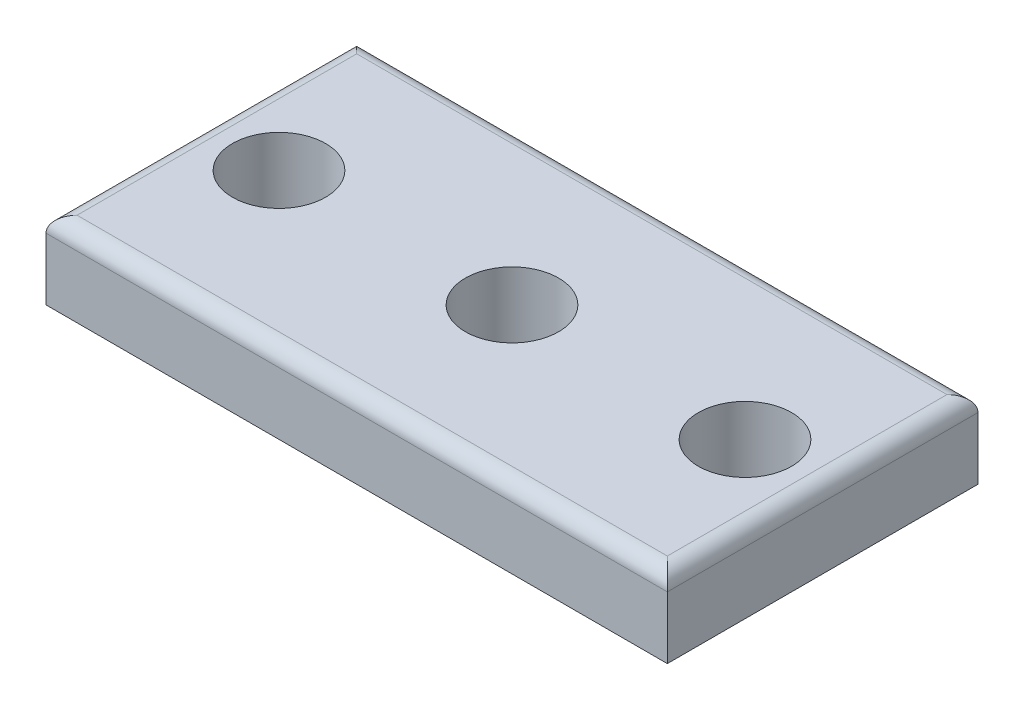
from build123d import *

# Parameters (mm, degrees)
SKETCH1_W           = 40
SKETCH1_H           = 20
SKETCH1_R           = 3
BOSS_EXTRUDE1_DEPTH = 5
FILLET1_R           = 1


with BuildPart() as part:
    # Sketch1 → Boss-Extrude1 (new body)
    with BuildSketch(Plane(origin=(0, 0, 0), x_dir=(1, 0, 0), z_dir=(0, 1, 0))):
        Rectangle(SKETCH1_W, SKETCH1_H)
        with Locations((-15, 0)):
            Circle(SKETCH1_R, mode=Mode.SUBTRACT)
        with Locations((15, 0)):
            Circle(SKETCH1_R, mode=Mode.SUBTRACT)
        Circle(SKETCH1_R, mode=Mode.SUBTRACT)
    extrude(amount=BOSS_EXTRUDE1_DEPTH)

    # Fillet1
    fillet1_edges = [part.edges().sort_by_distance(p)[0] for p in [
        (20, 5, 0),
        (0, 5, -10),
        (-20, 5, 0),
        (0, 5, 10),
    ]]
    fillet(fillet1_edges, radius=FILLET1_R)


solid = part.part
